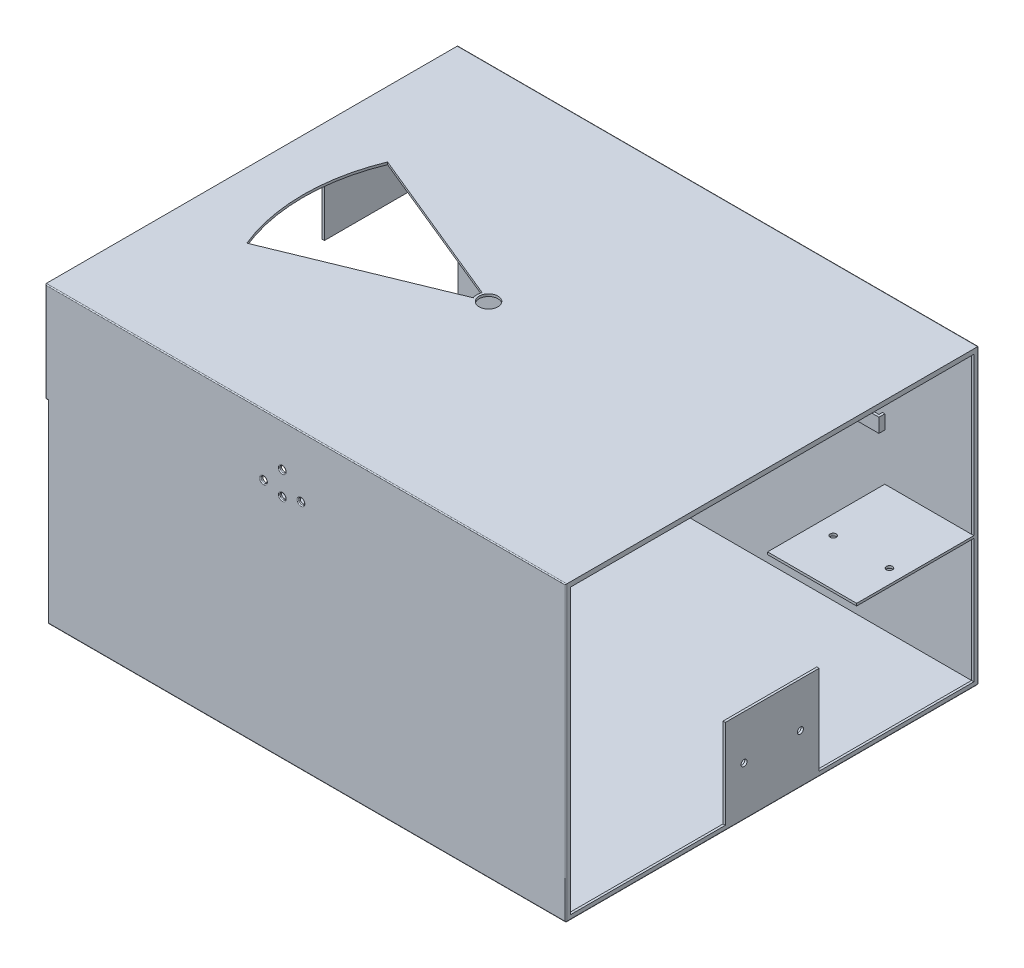
from build123d import *

# Parameters (mm, degrees)
SKETCH3_W               = 176
SKETCH3_H               = 125
SKETCH3_W_2             = 174
SKETCH3_H_2             = 123
BOSS_EXTRUDE1_DEPTH     = 220
BOSS_EXTRUDE3_DEPTH     = 181
SKETCH9_W               = 2.5
SKETCH9_H               = 6
BOSS_EXTRUDE4_DEPTH     = 1
SKETCH11_R              = 4
CUT_EXTRUDE1_DEPTH      = 1
SKETCH12_W              = 176
SKETCH12_H              = 42.5
BOSS_EXTRUDE5_DEPTH     = 1
SKETCH13_W              = 60
SKETCH13_H              = 30
CUT_EXTRUDE2_DEPTH      = 1
SKETCH18_R              = 1.3
CUT_EXTRUDE3_DEPTH      = 1
CUT_EXTRUDE3_DEPTH_BACK = 177
SKETCH20_R              = 1.3
CUT_EXTRUDE4_DEPTH      = 1
CUT_EXTRUDE4_DEPTH_BACK = 177
SKETCH22_W              = 176
SKETCH22_H              = 125
BOSS_EXTRUDE6_DEPTH     = 1
SKETCH23_R              = 1.3
CUT_EXTRUDE5_DEPTH      = 2
CUT_EXTRUDE6_DEPTH      = 2
FILLET5_R               = 0.4
SKETCH25_W              = 50
SKETCH25_H              = 1
BOSS_EXTRUDE7_DEPTH     = 50
SKETCH28_R              = 1.3
CUT_EXTRUDE7_DEPTH      = 1
SKETCH29_W              = 50
SKETCH29_H              = 1
BOSS_EXTRUDE9_DEPTH     = 40
SKETCH30_W              = 50
SKETCH30_H              = 1
CUT_EXTRUDE9_DEPTH      = 12
CUT_EXTRUDE11_REACH     = 59
SKETCH31_R              = 1.3
SKETCH32_W              = 50
SKETCH32_H              = 1
BOSS_EXTRUDE10_DEPTH    = 38
SKETCH33_R              = 1.3
CUT_EXTRUDE12_DEPTH     = 38
SKETCH34_W              = 50
SKETCH34_H              = 1
CUT_EXTRUDE13_DEPTH     = 38


with BuildPart() as part:
    # Sketch3 → Boss-Extrude1 (new body)
    with BuildSketch(Plane(origin=(0, 0, 0), x_dir=(0, 0, -1), z_dir=(1, 0, 0))):
        with Locations((-37, -96.283783784)):
            Rectangle(SKETCH3_W, SKETCH3_H)
        with Locations((-37, -96.283783784)):
            Rectangle(SKETCH3_W_2, SKETCH3_H_2, mode=Mode.SUBTRACT)
    extrude(amount=-BOSS_EXTRUDE1_DEPTH)

    # Sketch6 → Boss-Extrude3 (add)
    with BuildSketch(Plane.ZY.offset(220)):
        Polygon((-50, -82.783783784), (-48.5, -82.783783784), (-48.5, -77.783783784), (-47.5, -77.783783784), (-47.5, -82.783783784), (-47.5, -83.783783784), (-50, -83.783783784), align=None)
        Polygon((124, -82.783783784), (124, -83.783783784), (121.5, -83.783783784), (121.5, -82.783783784), (121.5, -77.783783784), (122.5, -77.783783784), (122.5, -82.783783784), align=None)
    extrude(amount=-BOSS_EXTRUDE3_DEPTH)

    # Sketch9 → Boss-Extrude4 (add)
    with BuildSketch(Plane(origin=(-39, 0, 0), x_dir=(0, 0, -1), z_dir=(1, 0, 0))):
        with Locations((-122.75, -80.783783784)):
            Rectangle(SKETCH9_W, SKETCH9_H)
        with Locations((48.75, -80.783783784)):
            Rectangle(SKETCH9_W, SKETCH9_H)
    extrude(amount=BOSS_EXTRUDE4_DEPTH)

    # Sketch11 → Cut-Extrude1 (cut)
    with BuildSketch(Plane(origin=(0, -33.783783784, 0), x_dir=(1, 0, 0), z_dir=(0, 1, 0))):
        with BuildLine():
            Line((-124.625452251, -35.101265823), (-193.082145562, -7))
            ThreePointArc((-193.082145562, -7), (-199, -37), (-193.082145562, -67))
            Line((-193.082145562, -67), (-124.625452251, -38.898734177))
            ThreePointArc((-124.625452251, -38.898734177), (-125, -37), (-124.625452251, -35.101265823))
        make_face()
        with Locations((-120, -37)):
            Circle(SKETCH11_R)
    extrude(amount=-CUT_EXTRUDE1_DEPTH, mode=Mode.SUBTRACT)

    # Sketch12 → Boss-Extrude5 (add)
    with BuildSketch(Plane.ZY.offset(220)):
        with Locations((37, -55.033783784)):
            Rectangle(SKETCH12_W, SKETCH12_H)
    extrude(amount=BOSS_EXTRUDE5_DEPTH)

    # Sketch13 → Cut-Extrude2 (cut)
    with BuildSketch(Plane.ZY.offset(221)):
        with Locations((37, -61.283783784)):
            Rectangle(SKETCH13_W, SKETCH13_H)
    extrude(amount=-CUT_EXTRUDE2_DEPTH, mode=Mode.SUBTRACT)

    # Sketch18 → Cut-Extrude3 (cut, two sides)
    with BuildSketch(Plane.XY.offset(125)) as cut_extrude3_sk:
        with Locations((-120, -51.923783784)):
            Circle(SKETCH18_R)
        with Locations((-120, -61.923783784)):
            Circle(SKETCH18_R)
    extrude(amount=CUT_EXTRUDE3_DEPTH, mode=Mode.SUBTRACT)
    extrude(cut_extrude3_sk.sketch, amount=-CUT_EXTRUDE3_DEPTH_BACK, mode=Mode.SUBTRACT)

    # Sketch20 → Cut-Extrude4 (cut, two sides)
    with BuildSketch(Plane.XY.offset(125)) as cut_extrude4_sk:
        with Locations((-128, -59.783783784)):
            Circle(SKETCH20_R)
        with Locations((-112, -59.783783784)):
            Circle(SKETCH20_R)
    extrude(amount=CUT_EXTRUDE4_DEPTH, mode=Mode.SUBTRACT)
    extrude(cut_extrude4_sk.sketch, amount=-CUT_EXTRUDE4_DEPTH_BACK, mode=Mode.SUBTRACT)

    # Sketch22 → Boss-Extrude6 (add)
    with BuildSketch(Plane(origin=(0, 0, 0), x_dir=(0, 0, -1), z_dir=(1, 0, 0))):
        with Locations((-37, -96.283783784)):
            Rectangle(SKETCH22_W, SKETCH22_H)
    extrude(amount=BOSS_EXTRUDE6_DEPTH)

    # Sketch23 → Cut-Extrude5 (cut)
    with BuildSketch(Plane(origin=(1, 0, 0), x_dir=(0, 0, -1), z_dir=(1, 0, 0))):
        with Locations((-49, -137.783783784)):
            Circle(SKETCH23_R)
        with Locations((-25, -137.783783784)):
            Circle(SKETCH23_R)
    extrude(amount=-CUT_EXTRUDE5_DEPTH, mode=Mode.SUBTRACT)

    # Sketch24 → Cut-Extrude6 (cut)
    with BuildSketch(Plane(origin=(1, 0, 0), x_dir=(0, 0, -1), z_dir=(1, 0, 0))):
        Polygon((-57, -156.783783784), (-57, -118.783783784), (-17, -118.783783784), (-17, -156.783783784), (49, -156.783783784), (49, -35.783783784), (-123, -35.783783784), (-123, -156.783783784), align=None)
    extrude(amount=-CUT_EXTRUDE6_DEPTH, mode=Mode.SUBTRACT)

    # Fillet5
    fillet5_edges = [part.edges().sort_by_distance(p)[0] for p in [
        (-220, -117.533783784, -51),
        (-220, -117.533783784, 125),
        (-220.5, -76.283783784, -51),
        (-220.5, -76.283783784, 125),
        (-221, -55.033783784, -51),
        (-221, -55.033783784, 125),
        (-121.3, -51.923783784, -51),
        (-121.3, -51.923783784, 125),
        (-220, -157.783783784, 37),
        (-121.3, -61.923783784, -51),
        (-121.3, -61.923783784, 125),
        (-129.3, -59.783783784, -51),
        (-129.3, -59.783783784, 125),
        (-113.3, -59.783783784, -51),
        (-113.3, -59.783783784, 125),
        (1, -96.283783784, 125),
        (1, -158.783783784, 37),
        (1, -96.283783784, -51),
        (-220, -158.783783784, 37),
        (-110, -33.783783784, 125),
        (-110, -33.783783784, -51),
        (-109.5, -158.783783784, -51),
        (-109.5, -158.783783784, 125),
    ]]
    fillet(fillet5_edges, radius=FILLET5_R)

    # Sketch25 → Boss-Extrude7 (add)
    with BuildSketch(Plane(origin=(1, 0, 0), x_dir=(0, 0, -1), z_dir=(1, 0, 0))):
        with Locations((24, -102.283783784)):
            Rectangle(SKETCH25_W, SKETCH25_H)
    extrude(amount=-BOSS_EXTRUDE7_DEPTH)

    # Sketch28 → Cut-Extrude7 (cut)
    with BuildSketch(Plane(origin=(0, -101.783783784, 0), x_dir=(1, 0, 0), z_dir=(0, 1, 0))):
        with Locations((-41, 19)):
            Circle(SKETCH28_R)
        with Locations((-17, 19)):
            Circle(SKETCH28_R)
    extrude(amount=-CUT_EXTRUDE7_DEPTH, mode=Mode.SUBTRACT)

    # Sketch29 → Boss-Extrude9 (add)
    with BuildSketch(Plane(origin=(1, 0, 0), x_dir=(0, 0, -1), z_dir=(1, 0, 0))):
        with Locations((24, -102.283783784)):
            Rectangle(SKETCH29_W, SKETCH29_H)
    extrude(amount=-BOSS_EXTRUDE9_DEPTH)

    # Sketch30 → Cut-Extrude9 (cut)
    with BuildSketch(Plane.ZY.offset(49)):
        with Locations((-24, -102.283783784)):
            Rectangle(SKETCH30_W, SKETCH30_H)
    extrude(amount=-CUT_EXTRUDE9_DEPTH, mode=Mode.SUBTRACT)

    # Sketch31 → Cut-Extrude11 (cut, up to next)
    with BuildSketch(Plane(origin=(0, -101.783783784, 0), x_dir=(1, 0, 0), z_dir=(0, 1, 0)), mode=Mode.PRIVATE) as cut_extrude11_sk1:
        with Locations((-29, 19)):
            Circle(SKETCH31_R)
    cut_extrude11_tool1 = extrude(cut_extrude11_sk1.sketch, amount=-CUT_EXTRUDE11_REACH, mode=Mode.PRIVATE) & part.part
    add(cut_extrude11_tool1.solids().sort_by_distance((-29, -101.783784, -19))[0], mode=Mode.SUBTRACT)
    # Sketch31 → Cut-Extrude11 (cut, up to next)
    with BuildSketch(Plane(origin=(0, -101.783783784, 0), x_dir=(1, 0, 0), z_dir=(0, 1, 0)), mode=Mode.PRIVATE) as cut_extrude11_sk2:
        with Locations((-5, 19)):
            Circle(SKETCH31_R)
    cut_extrude11_tool2 = extrude(cut_extrude11_sk2.sketch, amount=-CUT_EXTRUDE11_REACH, mode=Mode.PRIVATE) & part.part
    add(cut_extrude11_tool2.solids().sort_by_distance((-5, -101.783784, -19))[0], mode=Mode.SUBTRACT)

    # Sketch32 → Boss-Extrude10 (add)
    with BuildSketch(Plane(origin=(1, 0, 0), x_dir=(0, 0, -1), z_dir=(1, 0, 0))):
        with Locations((24, -103.283783784)):
            Rectangle(SKETCH32_W, SKETCH32_H)
    extrude(amount=-BOSS_EXTRUDE10_DEPTH)

    # Sketch33 → Cut-Extrude12 (cut)
    with BuildSketch(Plane(origin=(0, -101.783783784, 0), x_dir=(1, 0, 0), z_dir=(0, 1, 0))):
        with Locations((-29, 19)):
            Circle(SKETCH33_R)
        with Locations((-5, 19)):
            Circle(SKETCH33_R)
    extrude(amount=-CUT_EXTRUDE12_DEPTH, mode=Mode.SUBTRACT)

    # Sketch34 → Cut-Extrude13 (cut)
    with BuildSketch(Plane(origin=(1, 0, 0), x_dir=(0, 0, -1), z_dir=(1, 0, 0))):
        with Locations((24, -102.283783784)):
            Rectangle(SKETCH34_W, SKETCH34_H)
    extrude(amount=-CUT_EXTRUDE13_DEPTH, mode=Mode.SUBTRACT)


solid = part.part
